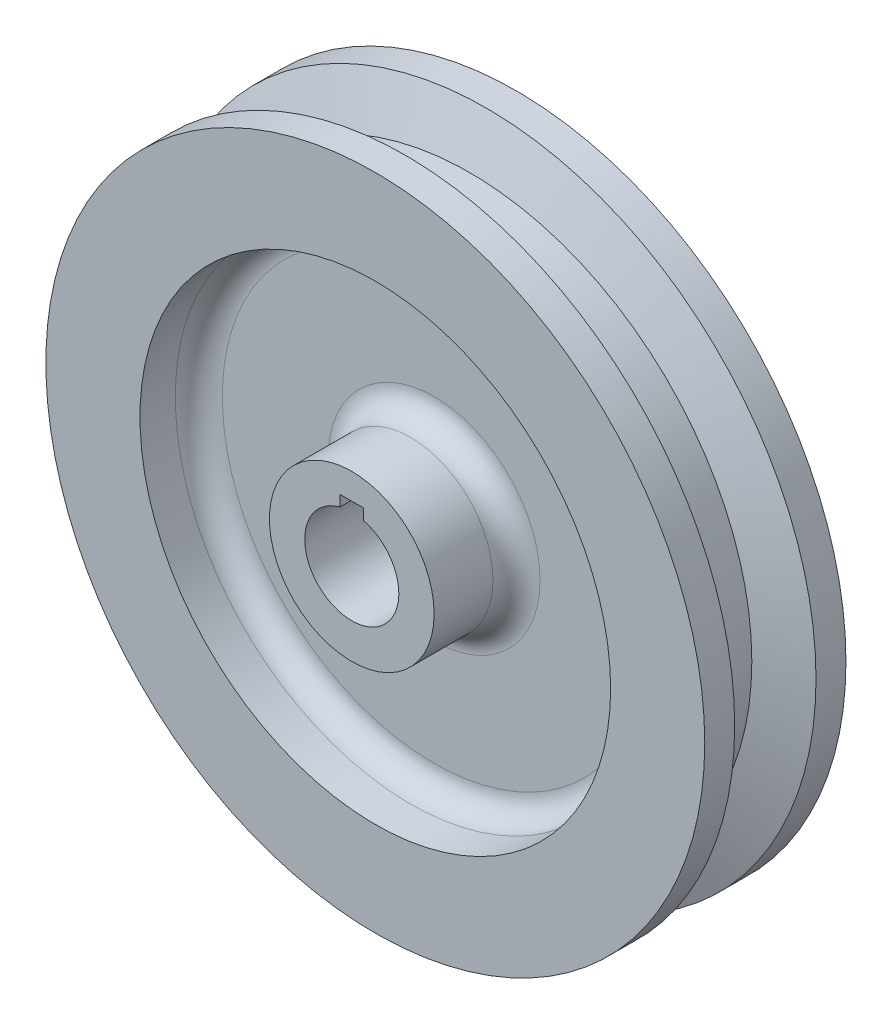
from build123d import *

# Parameters (mm, degrees)
SKETCH1_W          = 38.1
SKETCH1_H          = 25.4
SKETCH1_W_2        = 50.8
SKETCH1_H_2        = 9.525
SKETCH1_W_3        = 6.35
SKETCH1_H_3        = 41.275
FILLET1_R          = 6.35
SKETCH4_W          = 6.35
SKETCH4_H          = 15.24
CUT_EXTRUDE1_DEPTH = 51.8


with BuildPart() as part:
    # Sketch1 → Revolve1 (revolve)
    with BuildSketch(Plane(origin=(0, 0, 0), x_dir=(0, 0, -1), z_dir=(1, 0, 0))):
        with Locations((0, 76.2)):
            Rectangle(SKETCH1_W, SKETCH1_H)
        with Locations((0, 17.4625)):
            Rectangle(SKETCH1_W_2, SKETCH1_H_2)
        with Locations((0, 42.8625)):
            Rectangle(SKETCH1_W_3, SKETCH1_H_3)
    revolve(axis=Axis((0, 0, 0), (0, 0, -1)))

    # Sketch3 → Cut-Revolve1 (revolve, cut)
    with BuildSketch(Plane(origin=(0, 0, 0), x_dir=(0, 0, -1), z_dir=(1, 0, 0))):
        Polygon((-10.972421975, 88.9), (10.972421975, 88.9), (6.35, 76.2), (-6.35, 76.2), align=None)
    revolve(axis=Axis((0, 0, 0), (0, 0, -1)), mode=Mode.SUBTRACT)

    # Fillet1
    fillet1_edges = [part.edges().sort_by_distance(p)[0] for p in [
        (0, -63.5, -3.175),
        (0, -22.225, -3.175),
        (0, -22.225, 3.175),
        (0, -63.5, 3.175),
    ]]
    fillet(fillet1_edges, radius=FILLET1_R)

    # Sketch4 → Cut-Extrude1 (cut, through all)
    with BuildSketch(Plane.XY.offset(25.4)):
        with Locations((0, 7.62)):
            Rectangle(SKETCH4_W, SKETCH4_H)
    extrude(amount=-CUT_EXTRUDE1_DEPTH, mode=Mode.SUBTRACT)


solid = part.part
